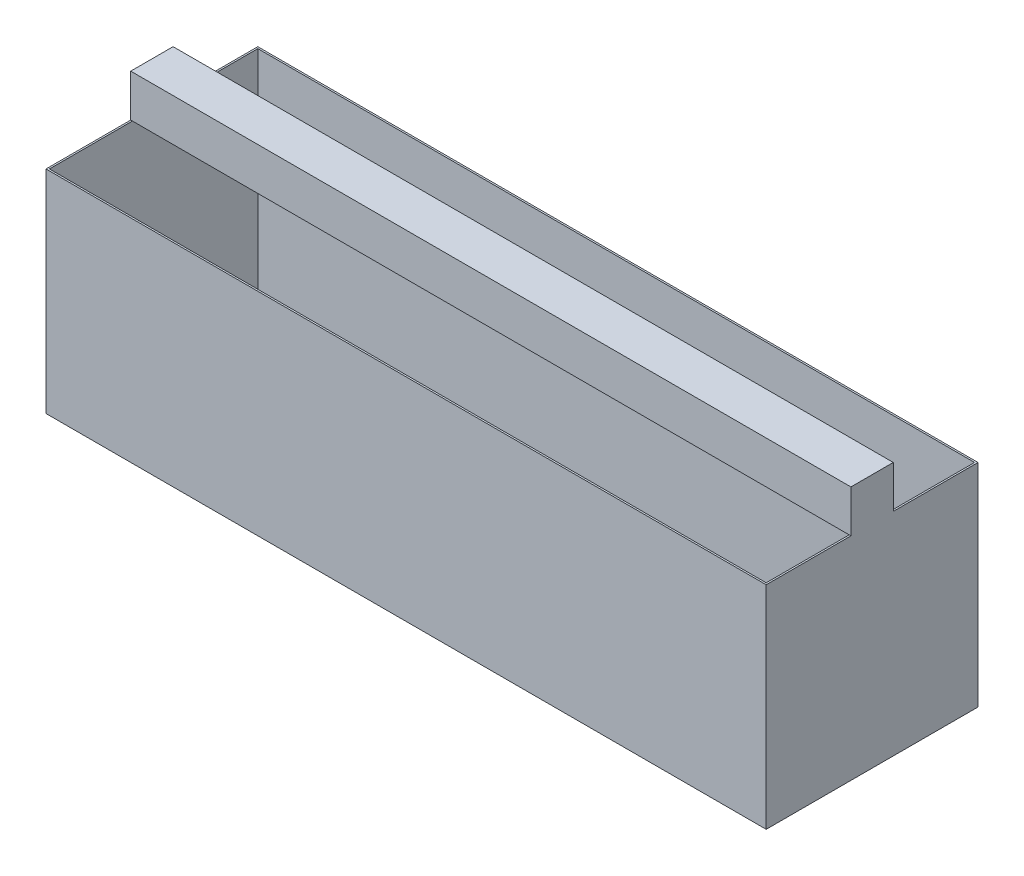
from build123d import *

# Parameters (mm, degrees)
SKETCH1_W           = 1700
SKETCH1_H           = 500
BOSS_EXTRUDE1_DEPTH = 500
SHELL1_T            = -4
SKETCH2_W           = 100
SKETCH2_H           = 100
BOSS_EXTRUDE2_DEPTH = 1700


with BuildPart() as part:
    # Sketch1 → Boss-Extrude1 (new body)
    with BuildSketch(Plane.XY):
        with Locations((850, 250)):
            Rectangle(SKETCH1_W, SKETCH1_H)
    extrude(amount=BOSS_EXTRUDE1_DEPTH)

    # Shell1
    shell1_openings = [part.faces().sort_by_distance(p)[0] for p in [
        (850, 500, 250),
    ]]
    offset(amount=SHELL1_T, openings=shell1_openings, kind=Kind.INTERSECTION)

    # Sketch2 → Boss-Extrude2 (add)
    with BuildSketch(Plane(origin=(1700, 0, 0), x_dir=(0, 0, -1), z_dir=(1, 0, 0))):
        with Locations((-250, 550)):
            Rectangle(SKETCH2_W, SKETCH2_H)
    extrude(amount=-BOSS_EXTRUDE2_DEPTH)


solid = part.part
